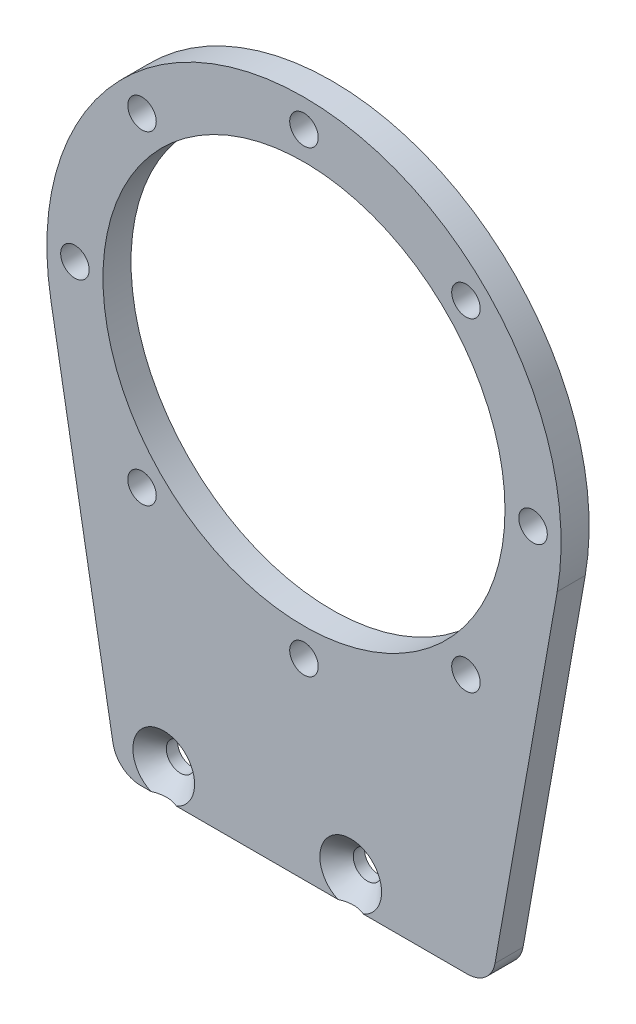
from build123d import *

# Parameters (mm, degrees)
EXTRUDE_1_DEPTH              = 3
SKETCH_2_R                   = 21.5
CUT_EXTRUDE_1_DEPTH          = 3
SKETCH_3_R                   = 1.525
CUT_EXTRUDE_2_DEPTH          = 3
FILLET_1_R                   = 3
SKETCH_4_R                   = 1.515
CUT_EXTRUDE_3_DEPTH          = 10
HOLE_WIZARD_M3_1_D           = 3
HOLE_WIZARD_M3_1_DEPTH       = 7.25
HOLE_WIZARD_M3_1_CSINK_D     = 6.6
HOLE_WIZARD_M3_1_CSINK_ANGLE = 90
HOLE_WIZARD_M3_1_TIP         = 0.901290929


with BuildPart() as part:
    # 草图1 → 凸台-拉伸1 (new body)
    with BuildSketch(Plane.XY):
        with BuildLine():
            Line((-20, -45), (20, -45))
            Line((20, -45), (27.083419191, -4.76848036))
            ThreePointArc((27.083419191, -4.76848036), (0, 27.5), (-27.083419191, -4.76848036))
            Line((-27.083419191, -4.76848036), (-20, -45))
        make_face()
    extrude(amount=EXTRUDE_1_DEPTH)

    # 草图2 → 切除-拉伸1 (cut)
    with BuildSketch(Plane.XY.offset(3)):
        Circle(SKETCH_2_R)
    extrude(amount=-CUT_EXTRUDE_1_DEPTH, mode=Mode.SUBTRACT)

    # 草图3 → 切除-拉伸2 (cut)
    with BuildSketch(Plane.XY.offset(3)):
        with Locations((17.324116139, 17.324116139)):
            Circle(SKETCH_3_R)
        with Locations((24.5, 0)):
            Circle(SKETCH_3_R)
        with Locations((17.324116139, -17.324116139)):
            Circle(SKETCH_3_R)
        with Locations((0, -24.5)):
            Circle(SKETCH_3_R)
        with Locations((-17.324116139, -17.324116139)):
            Circle(SKETCH_3_R)
        with Locations((-24.5, 0)):
            Circle(SKETCH_3_R)
        with Locations((-17.324116139, 17.324116139)):
            Circle(SKETCH_3_R)
        with Locations((0, 24.5)):
            Circle(SKETCH_3_R)
    extrude(amount=-CUT_EXTRUDE_2_DEPTH, mode=Mode.SUBTRACT)

    # 圆角1
    fillet_1_edges = [part.edges().sort_by_distance(p)[0] for p in [
        (20, -45, 1.5),
        (-20, -45, 1.5),
    ]]
    fillet(fillet_1_edges, radius=FILLET_1_R)

    # 草图4 → 切除-拉伸3 (cut)
    with BuildSketch(Plane.XY.offset(3)):
        with Locations((-15, -42)):
            Circle(SKETCH_4_R)
        with Locations((5, -42)):
            Circle(SKETCH_4_R)
    extrude(amount=-CUT_EXTRUDE_3_DEPTH, mode=Mode.SUBTRACT)

    # M3 十字槽沉头木螺钉的锥形沉头孔1
    with Locations(Plane.XY.offset(3)):
        with Locations((-15, -42), (5, -42)):
            CounterSinkHole(HOLE_WIZARD_M3_1_D / 2, HOLE_WIZARD_M3_1_CSINK_D / 2, depth=HOLE_WIZARD_M3_1_DEPTH, counter_sink_angle=HOLE_WIZARD_M3_1_CSINK_ANGLE)
            with Locations((0, 0, -(HOLE_WIZARD_M3_1_DEPTH + HOLE_WIZARD_M3_1_TIP / 2))):  # 118° drill point
                Cone(0, HOLE_WIZARD_M3_1_D / 2, HOLE_WIZARD_M3_1_TIP, mode=Mode.SUBTRACT)


solid = part.part
